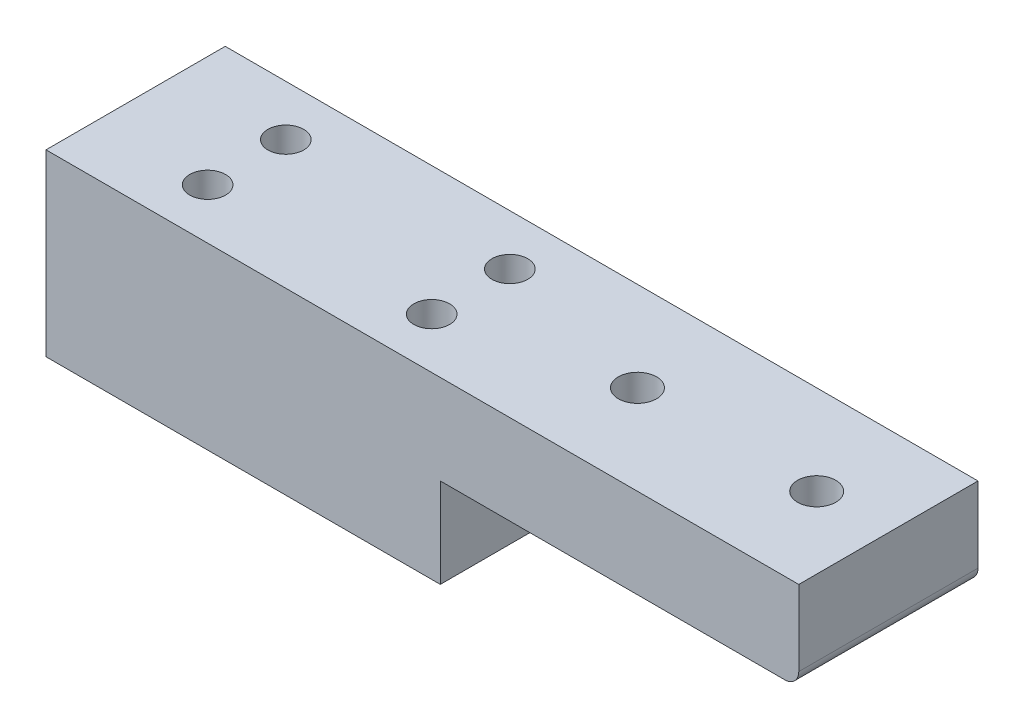
from build123d import *

# Parameters (mm, degrees)
SKETCH2_W                  = 25.4
SKETCH2_H                  = 12.7
BOSS_EXTRUDE1_DEPTH        = 6.35
SKETCH3_R                  = 0.5461
CUT_EXTRUDE1_DEPTH         = 7.35
SKETCH4_W                  = 50.8
SKETCH4_H                  = 12.7
BOSS_EXTRUDE2_DEPTH        = 6.35
F_8_0_199_DIAMETER_HOLE1_D = 2.54
F_6_32_TAPPED_HOLE3_D      = 2.7051
FILLET1_R                  = 1
SKETCH17_W                 = 12.7
SKETCH17_H                 = 12.7
BOSS_EXTRUDE3_DEPTH        = 2.54
F_6_32_TAPPED_HOLE4_D      = 2.7051
F_6_32_TAPPED_HOLE4_DEPTH  = 5.4864
F_6_32_TAPPED_HOLE4_TIP    = 0.81269403


with BuildPart() as part:
    # Sketch2 → Boss-Extrude1 (new body)
    with BuildSketch(Plane(origin=(0, 0, 0), x_dir=(1, 0, 0), z_dir=(0, 1, 0))):
        with Locations((12.7, -6.35)):
            Rectangle(SKETCH2_W, SKETCH2_H)
    extrude(amount=BOSS_EXTRUDE1_DEPTH)

    # Sketch3 → Cut-Extrude1 (cut, through all)
    with BuildSketch(Plane.XZ):
        with Locations((5.334, 9.1186)):
            Circle(SKETCH3_R)
        with Locations((5.334, 3.5814)):
            Circle(SKETCH3_R)
        with Locations((21.209, 3.5814)):
            Circle(SKETCH3_R)
        with Locations((21.209, 9.1186)):
            Circle(SKETCH3_R)
    extrude(amount=-CUT_EXTRUDE1_DEPTH, mode=Mode.SUBTRACT)

    # Sketch4 → Boss-Extrude2 (add)
    with BuildSketch(Plane(origin=(0, 6.35, 0), x_dir=(1, 0, 0), z_dir=(0, 1, 0))):
        with Locations((25.4, -6.35)):
            Rectangle(SKETCH4_W, SKETCH4_H)
    extrude(amount=BOSS_EXTRUDE2_DEPTH)

    # #8 (0.199) Diameter Hole1 (through all)
    with Locations(Plane(origin=(0, 0, 0), x_dir=(-1, 0, 0), z_dir=(0, -1, 0))):
        with Locations((-5.334, -3.5814), (-21.209, -3.5814), (-21.209, -9.1186), (-5.334, -9.1186)):
            Hole(F_8_0_199_DIAMETER_HOLE1_D / 2)

    # #6-32 Tapped Hole3 (through all)
    with Locations(Plane(origin=(0, 6.35, 0), x_dir=(-1, 0, 0), z_dir=(0, -1, 0))):
        with Locations((-33.02, -6.35), (-45.72, -6.35)):
            Hole(F_6_32_TAPPED_HOLE3_D / 2)

    # Fillet1
    fillet1_edges = [part.edges().sort_by_distance(p)[0] for p in [
        (50.8, 6.35, 6.35),
    ]]
    fillet(fillet1_edges, radius=FILLET1_R)

    # Sketch17 → Boss-Extrude3 (add)
    with BuildSketch(Plane.ZY):
        with Locations((6.35, 6.35)):
            Rectangle(SKETCH17_W, SKETCH17_H)
    extrude(amount=BOSS_EXTRUDE3_DEPTH)

    # #6-32 Tapped Hole4
    with Locations(Plane.ZY.offset(2.54)):
        with Locations((6.35, 6.35)):
            Hole(F_6_32_TAPPED_HOLE4_D / 2, depth=F_6_32_TAPPED_HOLE4_DEPTH)
            with Locations((0, 0, -(F_6_32_TAPPED_HOLE4_DEPTH + F_6_32_TAPPED_HOLE4_TIP / 2))):  # 118° drill point
                Cone(0, F_6_32_TAPPED_HOLE4_D / 2, F_6_32_TAPPED_HOLE4_TIP, mode=Mode.SUBTRACT)


solid = part.part
